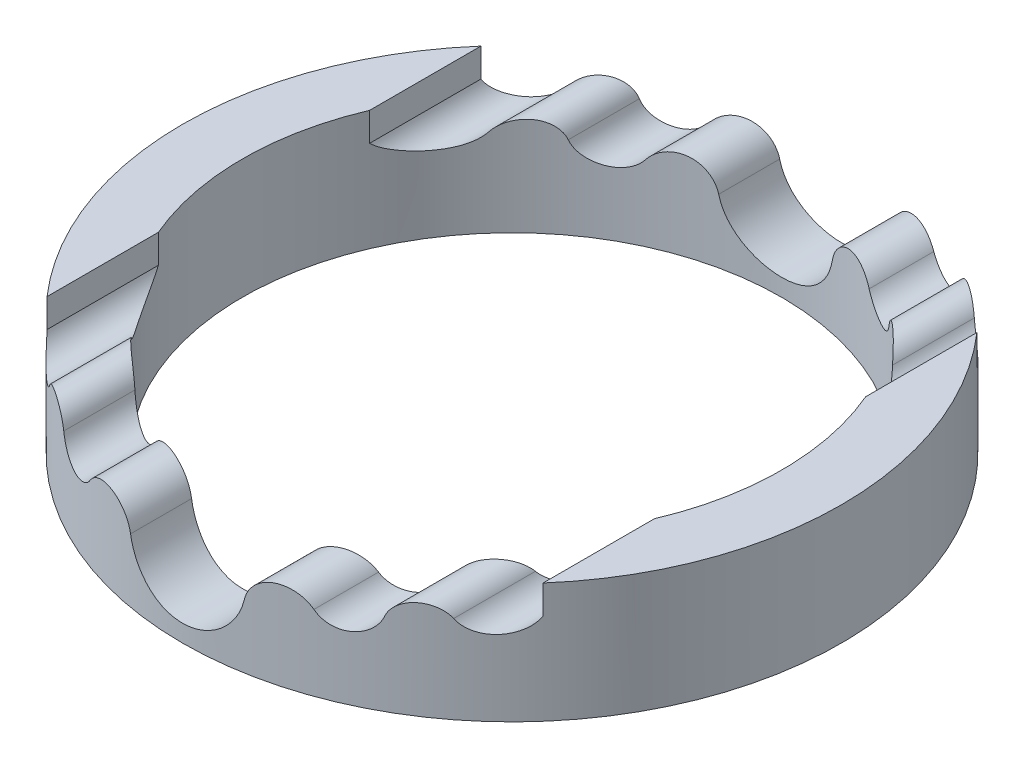
from build123d import *

# Parameters (mm, degrees)
SKETCH1_R               = 27.5
SKETCH1_R_2             = 22.5
BOSS_EXTRUDE1_DEPTH     = 5
CUT_EXTRUDE3_DEPTH      = 28.5
CUT_EXTRUDE3_DEPTH_BACK = 28.5


with BuildPart() as part:
    # Sketch1 → Boss-Extrude1 (new body, symmetric)
    with BuildSketch(Plane(origin=(0, 0, 0), x_dir=(1, 0, 0), z_dir=(0, 1, 0))):
        Circle(SKETCH1_R)
        Circle(SKETCH1_R_2, mode=Mode.SUBTRACT)
    extrude(amount=BOSS_EXTRUDE1_DEPTH, both=True)

    # Sketch3 → Cut-Extrude3 (cut, two sides)
    with BuildSketch(Plane.XY) as cut_extrude3_sk:
        with BuildLine():
            ThreePointArc((-4.74745791, 0.318346798), (-3.065358978, -2.467655845), (0, -3.56074408))
            Line((0, -3.56074408), (0, 5))
            Line((0, 5), (-20.700497525, 5))
            Line((-20.700497525, 5), (-20.700497525, 2.615010963))
            ThreePointArc((-20.700497525, 2.615010963), (-18.866910307, 1.311744504), (-16.85614269, 2.320386731))
            ThreePointArc((-16.85614269, 2.320386731), (-14.987432042, 3.204610911), (-13.38889815, 1.893648941))
            ThreePointArc((-13.38889815, 1.893648941), (-11.548514755, 0.343661099), (-9.334889148, 1.286706711))
            ThreePointArc((-9.334889148, 1.286706711), (-6.723222767, 2.308761406), (-4.74745791, 0.318346798))
        make_face()
        with BuildLine():
            Line((0, 5), (0, -3.56074408))
            ThreePointArc((0, -3.56074408), (3.065358978, -2.467655845), (4.74745791, 0.318346798))
            ThreePointArc((4.74745791, 0.318346798), (6.723222767, 2.308761406), (9.334889148, 1.286706711))
            ThreePointArc((9.334889148, 1.286706711), (11.548514755, 0.343661099), (13.38889815, 1.893648941))
            ThreePointArc((13.38889815, 1.893648941), (14.987432042, 3.204610911), (16.85614269, 2.320386731))
            ThreePointArc((16.85614269, 2.320386731), (18.866910307, 1.311744504), (20.700497525, 2.615010963))
            Line((20.700497525, 2.615010963), (20.700497525, 5))
            Line((20.700497525, 5), (0, 5))
        make_face()
    extrude(amount=CUT_EXTRUDE3_DEPTH, mode=Mode.SUBTRACT)
    extrude(cut_extrude3_sk.sketch, amount=-CUT_EXTRUDE3_DEPTH_BACK, mode=Mode.SUBTRACT)


solid = part.part
